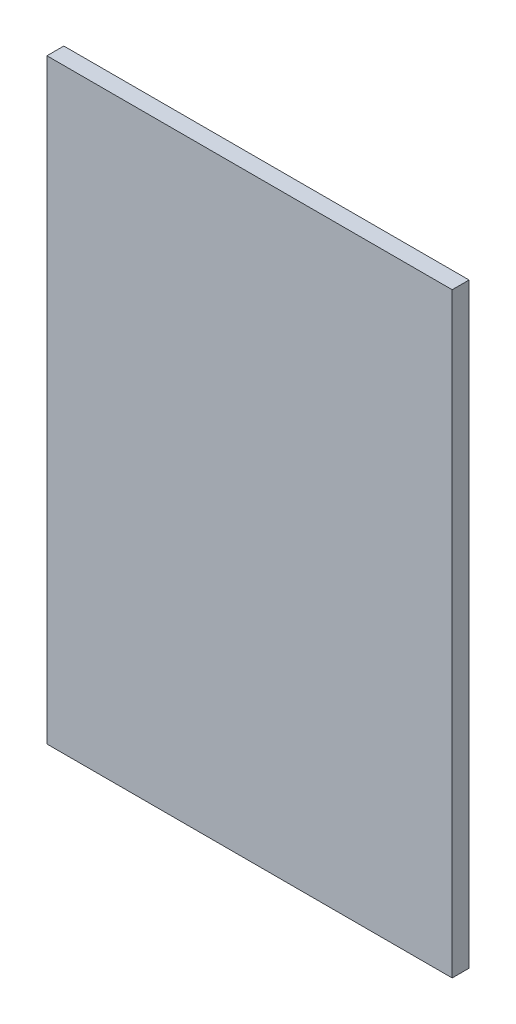
from build123d import *

# Parameters (mm, degrees)
SKETCH1_W           = 120
SKETCH1_H           = 180
BOSS_EXTRUDE1_DEPTH = 5
SKETCH2_W           = 8
SKETCH2_H           = 140
BOSS_EXTRUDE2_DEPTH = 14
SKETCH3_W           = 120
SKETCH3_H           = 3.5
CUT_EXTRUDE1_DEPTH  = 10


with BuildPart() as part:
    # Sketch1 → Boss-Extrude1 (new body)
    with BuildSketch(Plane.XY):
        Rectangle(SKETCH1_W, SKETCH1_H)
    extrude(amount=BOSS_EXTRUDE1_DEPTH)

    # Sketch2 → Boss-Extrude2 (add)
    with BuildSketch(Plane(origin=(0, 0, 0), x_dir=(-1, 0, 0), z_dir=(0, 0, -1))):
        with Locations((-11, 0)):
            Rectangle(SKETCH2_W, SKETCH2_H)
        with Locations((11, 0)):
            Rectangle(SKETCH2_W, SKETCH2_H)
    extrude(amount=BOSS_EXTRUDE2_DEPTH)

    # Sketch3 → Cut-Extrude1 (cut)
    with BuildSketch(Plane(origin=(0, 0, 0), x_dir=(-1, 0, 0), z_dir=(0, 0, -1))):
        with Locations((0, 88.25)):
            Rectangle(SKETCH3_W, SKETCH3_H)
    extrude(amount=-CUT_EXTRUDE1_DEPTH, mode=Mode.SUBTRACT)


solid = part.part
